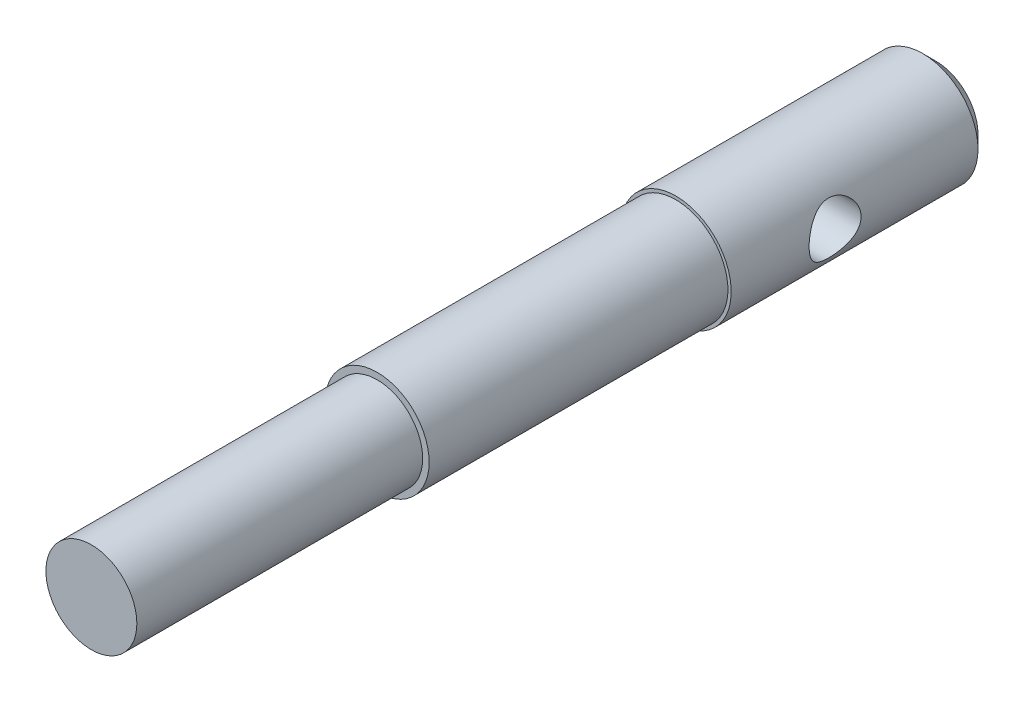
from build123d import *

# Parameters (mm, degrees)
SKIZZE1_R                            = 4
AUFSATZ_LINEAR_AUSTRAGEN1_DEPTH      = 65
SKIZZE2_R                            = 4.25
AUFSATZ_LINEAR_AUSTRAGEN2_DEPTH      = 20
SKIZZE3_R                            = 2
SCHNITT_LINEAR_AUSTRAGEN1_DEPTH      = 5.25
SCHNITT_LINEAR_AUSTRAGEN1_DEPTH_BACK = 5.25
FASE1_SIZE                           = 1
SKIZZE4_R                            = 4
SKIZZE4_R_2                          = 3.5
SCHNITT_LINEAR_AUSTRAGEN2_DEPTH      = 22


with BuildPart() as part:
    # Skizze1 → Aufsatz-Linear austragen1 (new body)
    with BuildSketch(Plane.XY):
        Circle(SKIZZE1_R)
    extrude(amount=AUFSATZ_LINEAR_AUSTRAGEN1_DEPTH)

    # Skizze2 → Aufsatz-Linear austragen2 (add)
    with BuildSketch(Plane(origin=(0, 0, 0), x_dir=(-1, 0, 0), z_dir=(0, 0, -1))):
        Circle(SKIZZE2_R)
    extrude(amount=-AUFSATZ_LINEAR_AUSTRAGEN2_DEPTH)

    # Skizze3 → Schnitt-Linear austragen1 (cut, two sides)
    with BuildSketch(Plane(origin=(0, 0, 0), x_dir=(0, 0, -1), z_dir=(1, 0, 0))) as schnitt_linear_austragen1_sk:
        with Locations((-12, 0)):
            Circle(SKIZZE3_R)
    extrude(amount=SCHNITT_LINEAR_AUSTRAGEN1_DEPTH, mode=Mode.SUBTRACT)
    extrude(schnitt_linear_austragen1_sk.sketch, amount=-SCHNITT_LINEAR_AUSTRAGEN1_DEPTH_BACK, mode=Mode.SUBTRACT)

    # Fase1
    fase1_edges = [part.edges().sort_by_distance(p)[0] for p in [
        (4.25, 0, 0),
    ]]
    chamfer(fase1_edges, length=FASE1_SIZE)

    # Skizze4 → Schnitt-Linear austragen2 (cut)
    with BuildSketch(Plane.XY.offset(65)):
        Circle(SKIZZE4_R)
        Circle(SKIZZE4_R_2, mode=Mode.SUBTRACT)
    extrude(amount=-SCHNITT_LINEAR_AUSTRAGEN2_DEPTH, mode=Mode.SUBTRACT)


solid = part.part
